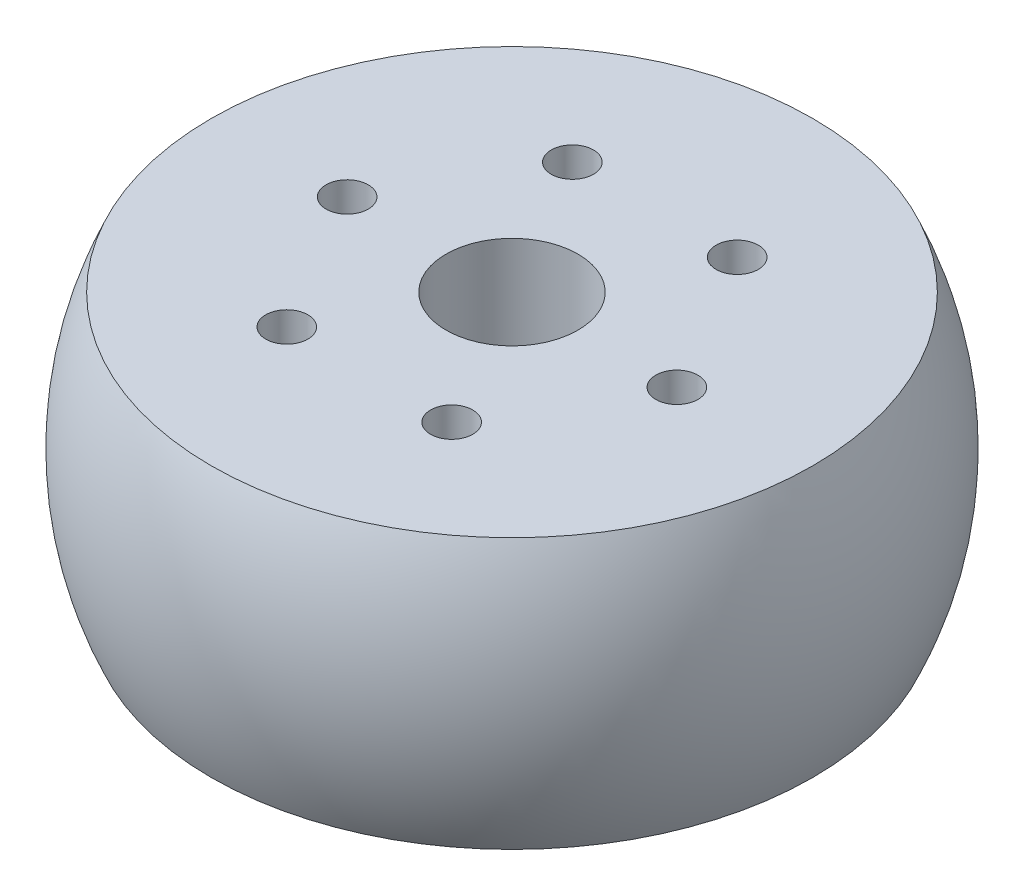
from build123d import *

# Parameters (mm, degrees)
SKETCH3_R          = 1.016
CUT_EXTRUDE1_DEPTH = 7.5
CIRPATTERN1_COUNT  = 6


with BuildPart() as part:
    # Sketch1 → Revolve1 (revolve)
    with BuildSketch(Plane(origin=(0, 0, 0), x_dir=(0, 0, -1), z_dir=(1, 0, 0))):
        with BuildLine():
            Line((3.175, 6.5), (14.483287783, 6.5))
            ThreePointArc((14.483287783, 6.5), (15.875, 0), (14.483287783, -6.5))
            Line((14.483287783, -6.5), (3.175, -6.5))
            Line((3.175, -6.5), (3.175, 6.5))
        make_face()
    revolve(axis=Axis((0, -6.5, 0), (0, 1, 0)))

    # Sketch3 → Cut-Extrude1 (cut, symmetric)
    with BuildSketch(Plane(origin=(0, 0, 0), x_dir=(1, 0, 0), z_dir=(0, 1, 0))):
        with Locations((7.9375, 0)):
            Circle(SKETCH3_R)
    cut_extrude1 = extrude(amount=CUT_EXTRUDE1_DEPTH, both=True, mode=Mode.SUBTRACT)

    # CirPattern1: Cut-Extrude1 ×6 about axis
    cirpattern1_axis = Axis((0, 0, 0), (0, 1, 0))
    for i in range(1, CIRPATTERN1_COUNT):
        add(cut_extrude1.rotate(cirpattern1_axis, i * 360 / CIRPATTERN1_COUNT), mode=Mode.SUBTRACT)


solid = part.part
